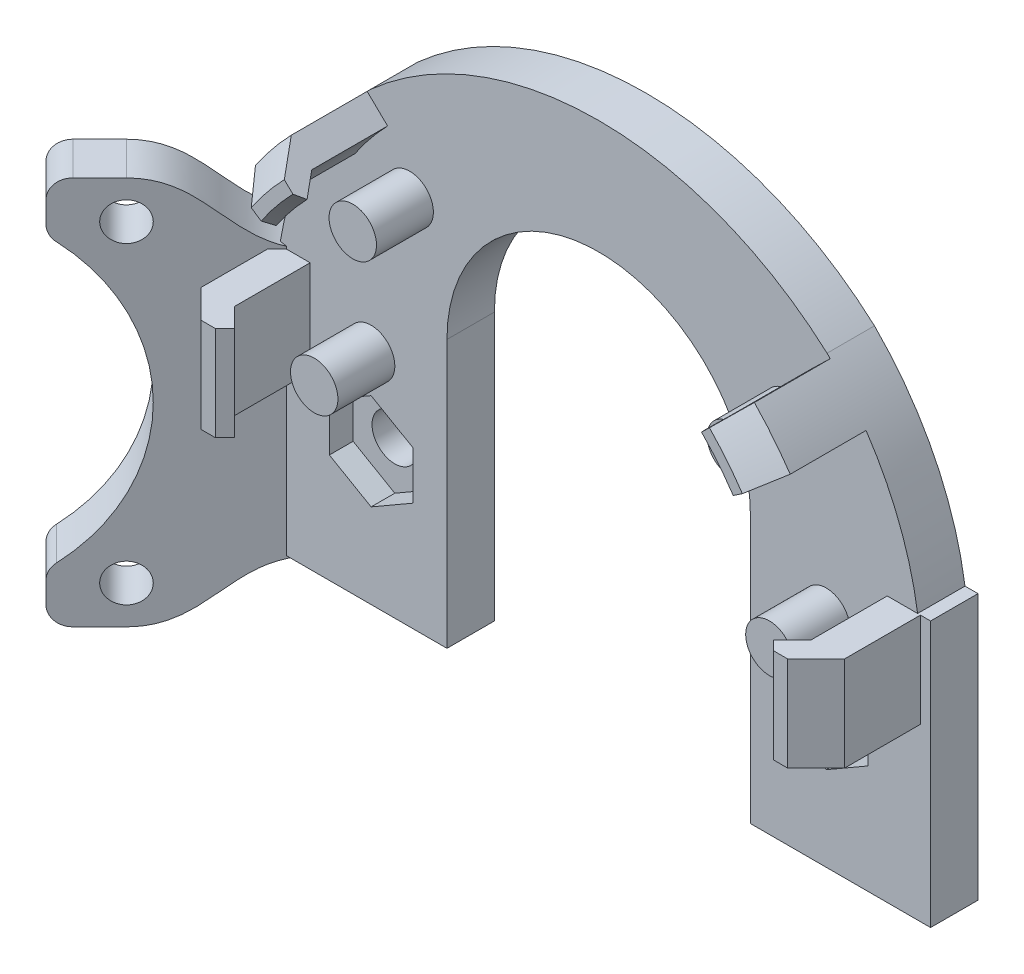
from build123d import *

# Parameters (mm, degrees)
SKETCH2_W                = 70
SKETCH2_H                = 28
BOSS_EXTRUDE1_DEPTH      = 5
CUT_NUT_DEPTH            = 2.5
SKETCH4_R                = 2.4
CUT_SCREW_DEPTH          = 38.7789624
SKETCH8_R                = 11
CUT_HOT_END_DEPTH        = 39.026306684
SKETCH11_W               = 22
SKETCH11_H               = 14
CUT_EXTRUDE8_DEPTH       = 39.026306684
BOSS_FAN_DEPTH           = 5
SKETCH9_R                = 2
CUT_FAN_SCREW_DEPTH      = 67.437703487
SKETCH10_R               = 18.5
CUT_EXTRUDE7_DEPTH       = 67.437703487
FILLET2_R                = 2
SKETCH12_W               = 3.5
SKETCH12_H               = 9.97245834
BOSS_BACK_HOOK_DEPTH     = 8
BOSS_BACK_HOOK_TOP_DEPTH = 9.97245834
SKETCH17_R               = 2.5
BOSS_EXTRUDE10_DEPTH     = 6
BOSS_FRONT_SUPPORT_REACH = 58.104
BOSS_FRONT_HOOK_DEPTH    = 8
SKETCH25_R               = 2.5
BOSS_FRONT_PIN_DEPTH     = 6
BOSS_FRONT_CURVE_DEPTH   = 5
CUT_EXTRUDE9_DEPTH       = 68.152189514


with BuildPart() as part:
    # Sketch2 → Boss-Extrude1 (new body)
    with BuildSketch(Plane.XY):
        Rectangle(SKETCH2_W, SKETCH2_H)
    extrude(amount=BOSS_EXTRUDE1_DEPTH)

    # Sketch3 → Cut-Nut (cut)
    with BuildSketch(Plane.XY.offset(5)):
        Polygon((28.4, 2.540341184), (24, 5.080682369), (19.6, 2.540341184), (19.6, -2.540341184), (24, -5.080682369), (28.4, -2.540341184), align=None)
    cut_nut = extrude(amount=-CUT_NUT_DEPTH, mode=Mode.SUBTRACT)

    # Sketch4 → Cut-Screw (cut, through all)
    with BuildSketch(Plane.XY.offset(2.5)):
        with Locations((24, 0)):
            Circle(SKETCH4_R)
    cut_screw = extrude(amount=-CUT_SCREW_DEPTH, mode=Mode.SUBTRACT)

    # Mirror1: Cut-Nut, Cut-Screw across plane
    add(cut_nut.mirror(Plane(origin=(0, 0, 0), x_dir=(0, 0, 1), z_dir=(1, 0, 0))), mode=Mode.SUBTRACT)
    add(cut_screw.mirror(Plane(origin=(0, 0, 0), x_dir=(0, 0, 1), z_dir=(1, 0, 0))), mode=Mode.SUBTRACT)

    # Sketch8 → Cut-Hot End (cut, through all)
    with BuildSketch(Plane.XY.offset(5)):
        Circle(SKETCH8_R)
    extrude(amount=-CUT_HOT_END_DEPTH, mode=Mode.SUBTRACT)

    # Sketch11 → Cut-Extrude8 (cut, through all)
    with BuildSketch(Plane.XY.offset(5)):
        with Locations((0, -7)):
            Rectangle(SKETCH11_W, SKETCH11_H)
    extrude(amount=-CUT_EXTRUDE8_DEPTH, mode=Mode.SUBTRACT)

    # Sketch6 → Boss-Fan (add)
    with BuildSketch(Plane(origin=(-17.5, 0, -17.5), x_dir=(-0.7071067811865488, 0, 0.7071067811865464), z_dir=(-0.7071067811865464, 0, -0.7071067811865488))):
        with BuildLine():
            Line((38.748737342, 20.5), (44.748737342, 20.5))
            Line((44.748737342, 20.5), (44.748737342, -20.5))
            Line((44.748737342, -20.5), (38.748737342, -20.5))
            add(Edge.make_bspline(
                [(24.748737342, -14), (30.971356168, -14), (32.526118515, -20.5), (38.748737342, -20.5)],
                knots=[0, 0, 0, 0, 1, 1, 1, 1], degree=3))
            Line((24.748737342, -14), (24.748737342, 14))
            add(Edge.make_bspline(
                [(24.748737342, 14), (30.971356168, 14), (32.526118515, 20.5), (38.748737342, 20.5)],
                knots=[0, 0, 0, 0, 1, 1, 1, 1], degree=3))
        make_face()
    extrude(amount=-BOSS_FAN_DEPTH)

    # Sketch9 → Cut-Fan Screw (cut, through all)
    with BuildSketch(Plane(origin=(-17.5, 0, -17.5), x_dir=(-0.7071067811865487, 1.3344026738283447e-14, 0.7071067811865464), z_dir=(-0.7071067811865464, 1.3877787807814728e-14, -0.7071067811865487))):
        with Locations((38.748737342, 16.5)):
            Circle(SKETCH9_R)
    cut_fan_screw = extrude(amount=-CUT_FAN_SCREW_DEPTH, mode=Mode.SUBTRACT)

    # Mirror-Fan Screw: Cut-Fan Screw across plane
    add(cut_fan_screw.mirror(Plane.ZX), mode=Mode.SUBTRACT)

    # Sketch10 → Cut-Extrude7 (cut, through all)
    with BuildSketch(Plane(origin=(-17.5, 0, -17.5), x_dir=(-0.7071067811865488, 1.4278108609963275e-14, 0.7071067811865464), z_dir=(-0.7071067811865464, 1.3877787807814742e-14, -0.7071067811865488))):
        with Locations((55.248737342, 0)):
            Circle(SKETCH10_R)
    extrude(amount=-CUT_EXTRUDE7_DEPTH, mode=Mode.SUBTRACT)

    # Fillet2
    fillet2_edges = [part.edges().sort_by_distance(p)[0] for p in [
        (-47.374368671, -15.231546212, 15.909902577),
        (-47.374368671, 15.231546212, 15.909902577),
        (-47.374368671, 20.5, 15.909902577),
        (-47.374368671, -20.5, 15.909902577),
    ]]
    fillet(fillet2_edges, radius=FILLET2_R)

    # Sketch12 → Boss-Back Hook (add)
    with BuildSketch(Plane.XY.offset(5)):
        with Locations((-32.178932188, 9.01377083)):
            Rectangle(SKETCH12_W, SKETCH12_H)
    boss_back_hook = extrude(amount=BOSS_BACK_HOOK_DEPTH)

    # Sketch14 → Boss-Back Hook Top (add)
    with BuildSketch(Plane.XZ.offset(-4.02754166)):
        Polygon((-30.428932188, 13), (-28.428932188, 15), (-29.428932188, 16), (-30.928932188, 16), (-33.928932188, 13), align=None)
    boss_back_hook_top = extrude(amount=-BOSS_BACK_HOOK_TOP_DEPTH)

    # Mirror-Back Hook: Boss-Back Hook, Boss-Back Hook Top across plane
    add(boss_back_hook.mirror(Plane(origin=(0, 0, 0), x_dir=(0, 0, 1), z_dir=(1, 0, 0))))
    add(boss_back_hook_top.mirror(Plane(origin=(0, 0, 0), x_dir=(0, 0, 1), z_dir=(1, 0, 0))))

    # Sketch17 → Boss-Extrude10 (add)
    with BuildSketch(Plane.XY.offset(5)):
        with Locations(Location((-24, 9.01377083, 0), (0, 0, 180))):
            Circle(SKETCH17_R)
        with Locations(Location((24, 9.01377083, 0), (0, 0, 180))):
            Circle(SKETCH17_R)
    extrude(amount=BOSS_EXTRUDE10_DEPTH)

    # Boss-Front Support: up to this face of the body (flat: up to its plane)
    boss_front_support_end = Plane(part.part.faces().sort_by_distance((23, -13.265266046, 5))[0])
    # Sketch20 → Boss-Front Support (add, up to the picked face)
    with BuildSketch(Plane(origin=(0, 0, 0), x_dir=(-1, 0, 0), z_dir=(0, 0, -1)), mode=Mode.PRIVATE) as boss_front_support_sk1:
        with BuildLine():
            Line((24.083189158, 33), (15.583240043, 24.529411765))
            ThreePointArc((15.583240043, 24.529411765), (19.23814858, 19.67209629), (21.424285286, 14))
            Line((21.424285286, 14), (33.630343442, 14))
            ThreePointArc((33.630343442, 14), (30.380305483, 24.265550718), (24.083189158, 33))
        make_face()
    boss_front_support_tool1 = split(extrude(boss_front_support_sk1.sketch, amount=-BOSS_FRONT_SUPPORT_REACH, mode=Mode.PRIVATE), bisect_by=boss_front_support_end, keep=Keep.BOTH, mode=Mode.PRIVATE)
    boss_front_support = boss_front_support_tool1.solids().sort_by(Axis((-24.942204, 21.980876, 0), (0, 0, 1)))[0]
    add(boss_front_support)

    # Sketch21 → Boss-Front Hook (add)
    with BuildSketch(Plane.XY.offset(5)):
        with BuildLine():
            Line((-24.416846712, 32.660464844), (-22.262419061, 30.57277677))
            ThreePointArc((-22.262419061, 30.57277677), (-24.079068363, 28.524304515), (-25.707884563, 26.323529412))
            Line((-25.707884563, 26.323529412), (-28.19574436, 28))
            ThreePointArc((-28.19574436, 28), (-26.409300785, 30.413753339), (-24.416846712, 32.660464844))
        make_face()
    boss_front_hook = extrude(amount=BOSS_FRONT_HOOK_DEPTH)

    # Sweep-Front Hook Top: sweep along a curve in space
    with BuildLine() as sweep_front_hook_top_path:
        ThreePointArc((-25.707884563, 26.323529412, 13), (-24.079068363, 28.524304515, 13), (-22.262419061, 30.57277677, 13))
    # Sketch22 → Sweep-Front Hook Top (sweep)
    with BuildSketch(Plane(origin=(4.752413936, 4.394805718, 0), x_dir=(0, 0, -1), z_dir=(0.6958960248359726, 0.7181425503460238, 0))):
        Polygon((-13, 37.617647059), (-13, 40.617647059), (-15.611662163, 38.005984896), (-15.611662163, 36.747093005), (-14.741108108, 35.87653895), align=None)
    sweep(path=sweep_front_hook_top_path.line)

    # Sketch25 → Boss-Front Pin (add)
    with BuildSketch(Plane.XY.offset(5)):
        with Locations(Location((-19.93223769, 25.111248957, 0), (0, 0, 180))):
            Circle(SKETCH25_R)
    boss_front_pin = extrude(amount=BOSS_FRONT_PIN_DEPTH)

    # Sketch23 → Boss-Front Curve (add)
    with BuildSketch(Plane(origin=(0, 0, 0), x_dir=(-1, 0, 0), z_dir=(0, 0, -1))):
        with BuildLine():
            Line((0, 42.213351454), (0, 14))
            Line((0, 14), (33.630343442, 14))
            Line((33.630343442, 14), (24.083189158, 33))
            ThreePointArc((24.083189158, 33), (12.892690226, 39.831392494), (0, 42.213351454))
        make_face()
    boss_front_curve = extrude(amount=-BOSS_FRONT_CURVE_DEPTH)

    # Mirror5: Boss-Front Support, Boss-Front Hook, Boss-Front Pin, Boss-Front Curve across plane
    add(boss_front_support.mirror(Plane(origin=(0, 0, 0), x_dir=(0, 0, 1), z_dir=(1, 0, 0))))
    add(boss_front_hook.mirror(Plane(origin=(0, 0, 0), x_dir=(0, 0, 1), z_dir=(1, 0, 0))))
    add(boss_front_pin.mirror(Plane(origin=(0, 0, 0), x_dir=(0, 0, 1), z_dir=(1, 0, 0))))
    add(boss_front_curve.mirror(Plane(origin=(0, 0, 0), x_dir=(0, 0, 1), z_dir=(1, 0, 0))))

    # Sweep2: sweep along a curve in space
    with BuildLine() as sweep2_path:
        ThreePointArc((25.707884563, 26.323529412, 13), (24.079068363, 28.524304515, 13), (22.262419061, 30.57277677, 13))
    # Sketch24 → Sweep2 (sweep)
    with BuildSketch(Plane(origin=(-4.170823776, 6.189446367, 0), x_dir=(0.8292865988159824, 0.5588235294117634, 0), z_dir=(0.5588235294117634, -0.8292865988159824, 0))):
        Polygon((36.029411765, 13), (39.029411765, 13), (36.273559232, 15.755852533), (35.110794254, 15.755852533), (34.192176743, 14.837235022), align=None)
    sweep(path=sweep2_path.line)

    # Sketch26 → Cut-Extrude9 (cut, through all)
    with BuildSketch(Plane(origin=(0, 0, 0), x_dir=(-1, 0, 0), z_dir=(0, 0, -1))):
        with BuildLine():
            Line((-16, -14), (-16, 14.213351454))
            ThreePointArc((-16, 14.213351454), (0, 30.213351454), (16, 14.213351454))
            Line((16, 14.213351454), (16, -14))
            Line((16, -14), (-16, -14))
        make_face()
    extrude(amount=-CUT_EXTRUDE9_DEPTH, mode=Mode.SUBTRACT)


solid = part.part
